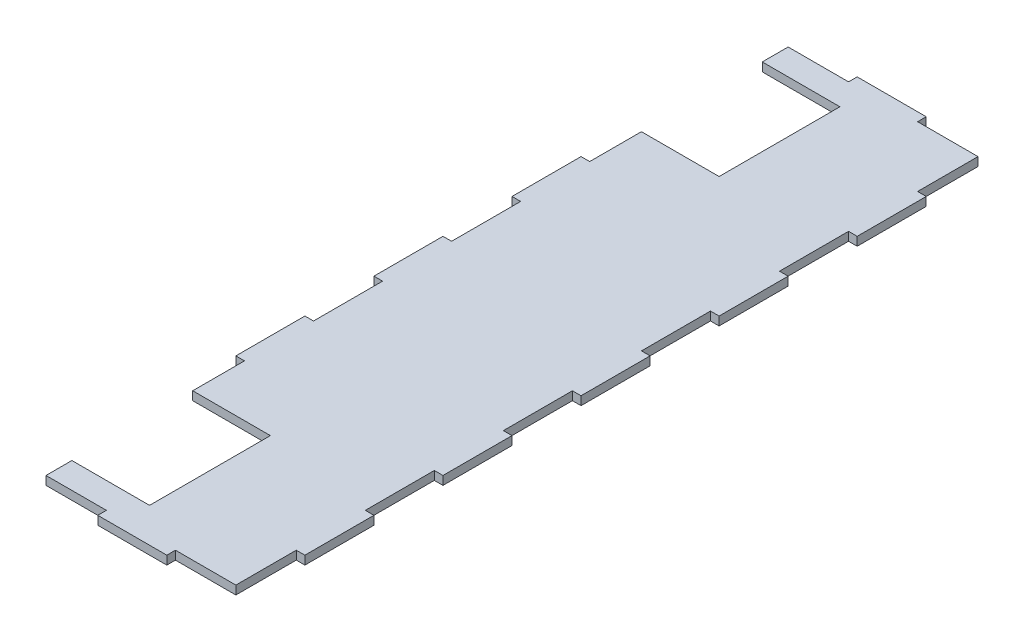
from build123d import *

# Parameters (mm, degrees)
BOSS_EXTRUDE1_DEPTH     = 3.175
SKETCH2_W               = 31.75
SKETCH2_H               = 44.45
CUT_EXTRUDE1_DEPTH      = 1
CUT_EXTRUDE1_DEPTH_BACK = 4.175


with BuildPart() as part:
    # Sketch1 → Boss-Extrude1 (new body)
    with BuildSketch(Plane(origin=(0, 0, 0), x_dir=(1, 0, 0), z_dir=(0, 1, 0))):
        Polygon((0, 0), (-38.1, 0), (-38.1, 12.7), (-34.925, 12.7), (-34.925, 38.1), (-38.1, 38.1), (-38.1, 63.5), (-34.925, 63.5), (-34.925, 88.9), (-38.1, 88.9), (-38.1, 114.3), (-34.925, 114.3), (-34.925, 136.525), (-12.7, 136.525), (-12.7, 139.7), (0, 139.7), align=None)
    extrude(amount=BOSS_EXTRUDE1_DEPTH)

    # Mirror1: part across plane


with BuildPart() as part_1:
    add(part.part)
    add(part.part.mirror(Plane(origin=(0, 3.175, 0), x_dir=(0, 0, 1), z_dir=(-1, 0, 0))))

    # Sketch2 → Cut-Extrude1 (cut, two sides)
    with BuildSketch(Plane(origin=(0, 3.175, 0), x_dir=(1, 0, 0), z_dir=(0, 1, 0))) as cut_extrude1_sk:
        with Locations((-22.225, 104.775)):
            Rectangle(SKETCH2_W, SKETCH2_H)
    extrude(amount=CUT_EXTRUDE1_DEPTH, mode=Mode.SUBTRACT)
    extrude(cut_extrude1_sk.sketch, amount=-CUT_EXTRUDE1_DEPTH_BACK, mode=Mode.SUBTRACT)

    # Mirror2: part across plane


with BuildPart() as part_2:
    add(part_1.part)
    add(part_1.part.mirror(Plane(origin=(0, 3.175, 0), x_dir=(1, 0, 0), z_dir=(0, 0, 1))))


solid = part_2.part
